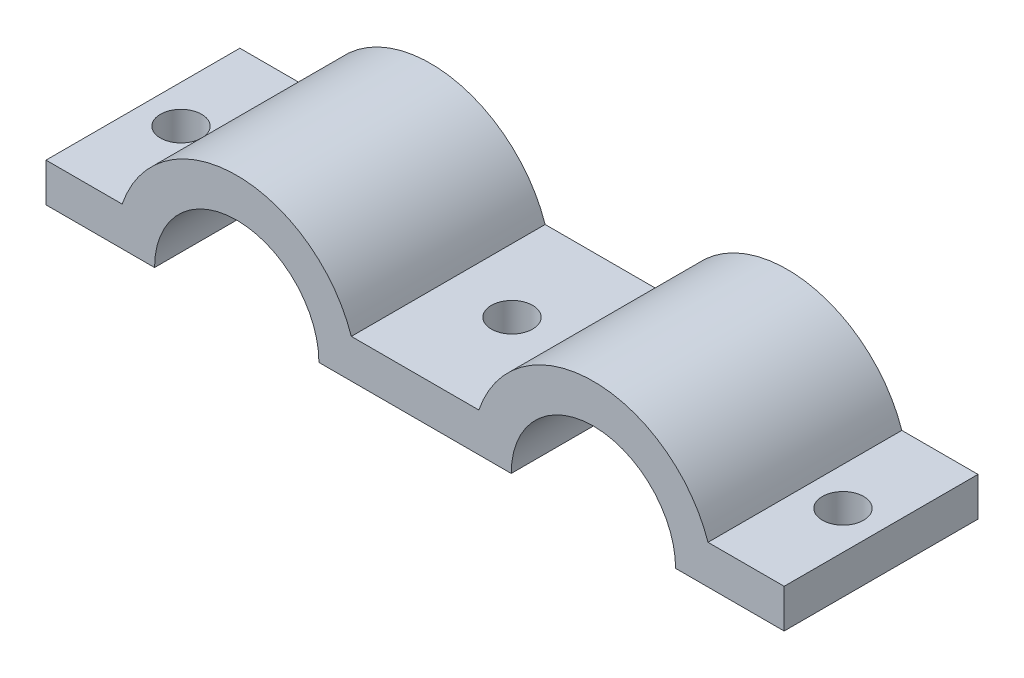
from build123d import *

# Parameters (mm, degrees)
BOSS_EXTRUDE1_DEPTH = 31.75
SKETCH3_R           = 3.3782
CUT_EXTRUDE1_DEPTH  = 7.35


with BuildPart() as part:
    # Sketch1 → Boss-Extrude1 (new body)
    with BuildSketch(Plane.XY):
        with BuildLine():
            Line((12.475198354, 6.35), (0, 6.35))
            Line((0, 6.35), (0, 0))
            Line((0, 0), (17.78, 0))
            ThreePointArc((17.78, 0), (31.242, 13.462), (44.704, 0))
            Line((44.704, 0), (76.2, 0))
            ThreePointArc((76.2, 0), (89.662, 13.462), (103.124, 0))
            Line((103.124, 0), (120.904, 0))
            Line((120.904, 0), (120.904, 6.35))
            Line((120.904, 6.35), (108.428801646, 6.35))
            ThreePointArc((108.428801646, 6.35), (89.662, 19.812), (70.895198354, 6.35))
            Line((70.895198354, 6.35), (50.008801646, 6.35))
            ThreePointArc((50.008801646, 6.35), (31.242, 19.812), (12.475198354, 6.35))
        make_face()
    extrude(amount=BOSS_EXTRUDE1_DEPTH)

    # Sketch3 → Cut-Extrude1 (cut, through all)
    with BuildSketch(Plane(origin=(0, 6.35, 0), x_dir=(1, 0, 0), z_dir=(0, 1, 0))):
        with Locations((6.237599177, -15.875)):
            Circle(SKETCH3_R)
        with Locations((60.452, -15.875)):
            Circle(SKETCH3_R)
        with Locations((114.666400823, -15.875)):
            Circle(SKETCH3_R)
    extrude(amount=-CUT_EXTRUDE1_DEPTH, mode=Mode.SUBTRACT)


solid = part.part
